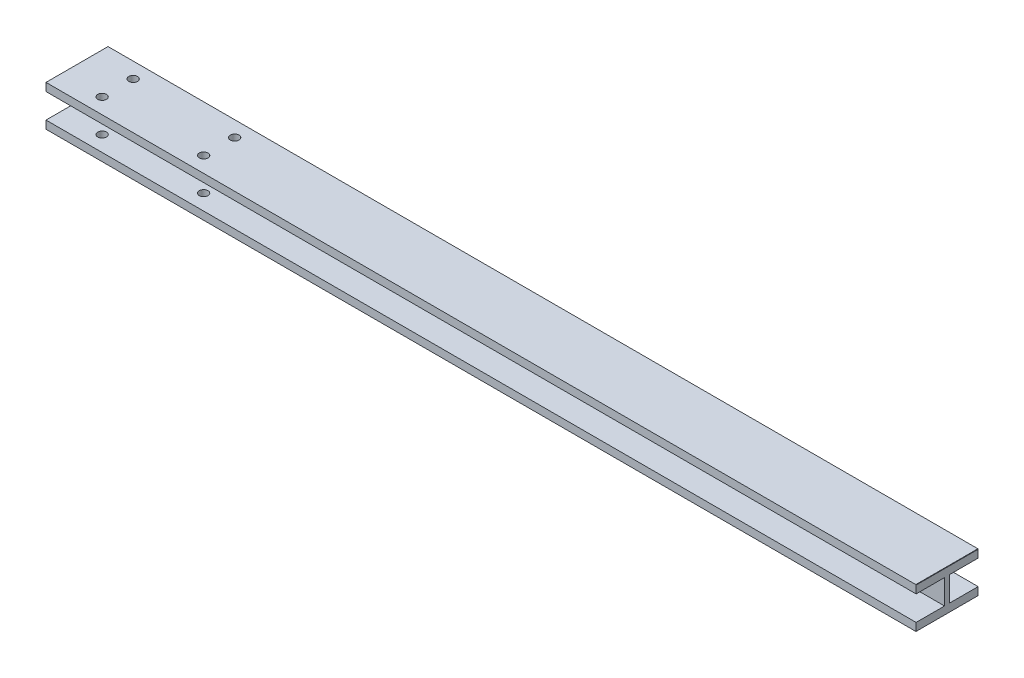
from build123d import *

# Parameters (mm, degrees)
SKETCH1_W           = 3000
SKETCH1_H           = 213.9
SKETCH1_R           = 15
BOSS_EXTRUDE1_DEPTH = 140
SKETCH2_W           = 3
SKETCH2_H           = 6
CUT_EXTRUDE1_DEPTH  = 0.1
SKETCH4_W           = 98
SKETCH4_H           = 85
CUT_EXTRUDE3_DEPTH  = 3001
SKETCH5_W           = 1
SKETCH5_H           = 213.9
CUT_EXTRUDE4_DEPTH  = 1
SKETCH6_W           = 0.5
SKETCH6_H           = 139
CUT_EXTRUDE5_DEPTH  = 0.5
SKETCH7_W           = 1
SKETCH7_H           = 213.9
CUT_EXTRUDE6_DEPTH  = 0.5


with BuildPart() as part:
    # Sketch1 → Boss-Extrude1 (new body)
    with BuildSketch(Plane(origin=(0, 0, 0), x_dir=(1, 0, 0), z_dir=(0, 1, 0))):
        with Locations((1500, -106.95)):
            Rectangle(SKETCH1_W, SKETCH1_H)
        with Locations((140, -53.475)):
            Circle(SKETCH1_R, mode=Mode.SUBTRACT)
        with Locations((140, -160.425)):
            Circle(SKETCH1_R, mode=Mode.SUBTRACT)
        with Locations((490, -53.475)):
            Circle(SKETCH1_R, mode=Mode.SUBTRACT)
        with Locations((490, -160.425)):
            Circle(SKETCH1_R, mode=Mode.SUBTRACT)
    extrude(amount=BOSS_EXTRUDE1_DEPTH)

    # Sketch2 → Cut-Extrude1 (cut)
    with BuildSketch(Plane.XZ):
        with Locations((2998.5, 106.95)):
            Rectangle(SKETCH2_W, SKETCH2_H)
    extrude(amount=-CUT_EXTRUDE1_DEPTH, mode=Mode.SUBTRACT)

    # Sketch4 → Cut-Extrude3 (cut, through all)
    with BuildSketch(Plane(origin=(3000, 0, 0), x_dir=(0, 0, -1), z_dir=(1, 0, 0))):
        with Locations((-164.9, 70)):
            Rectangle(SKETCH4_W, SKETCH4_H)
        with Locations((-49, 70)):
            Rectangle(SKETCH4_W, SKETCH4_H)
    extrude(amount=-CUT_EXTRUDE3_DEPTH, mode=Mode.SUBTRACT)

    # Sketch5 → Cut-Extrude4 (cut)
    with BuildSketch(Plane(origin=(0, 140, 0), x_dir=(1, 0, 0), z_dir=(0, 1, 0))):
        with Locations((2999.5, -106.95)):
            Rectangle(SKETCH5_W, SKETCH5_H)
    extrude(amount=-CUT_EXTRUDE4_DEPTH, mode=Mode.SUBTRACT)

    # Sketch6 → Cut-Extrude5 (cut)
    with BuildSketch(Plane(origin=(0, 0, 0), x_dir=(-1, 0, 0), z_dir=(0, 0, -1))):
        with Locations((-2999.75, 69.5)):
            Rectangle(SKETCH6_W, SKETCH6_H)
    extrude(amount=-CUT_EXTRUDE5_DEPTH, mode=Mode.SUBTRACT)

    # Sketch7 → Cut-Extrude6 (cut)
    with BuildSketch(Plane.XZ):
        with Locations((2999.5, 106.95)):
            Rectangle(SKETCH7_W, SKETCH7_H)
    extrude(amount=-CUT_EXTRUDE6_DEPTH, mode=Mode.SUBTRACT)


solid = part.part
